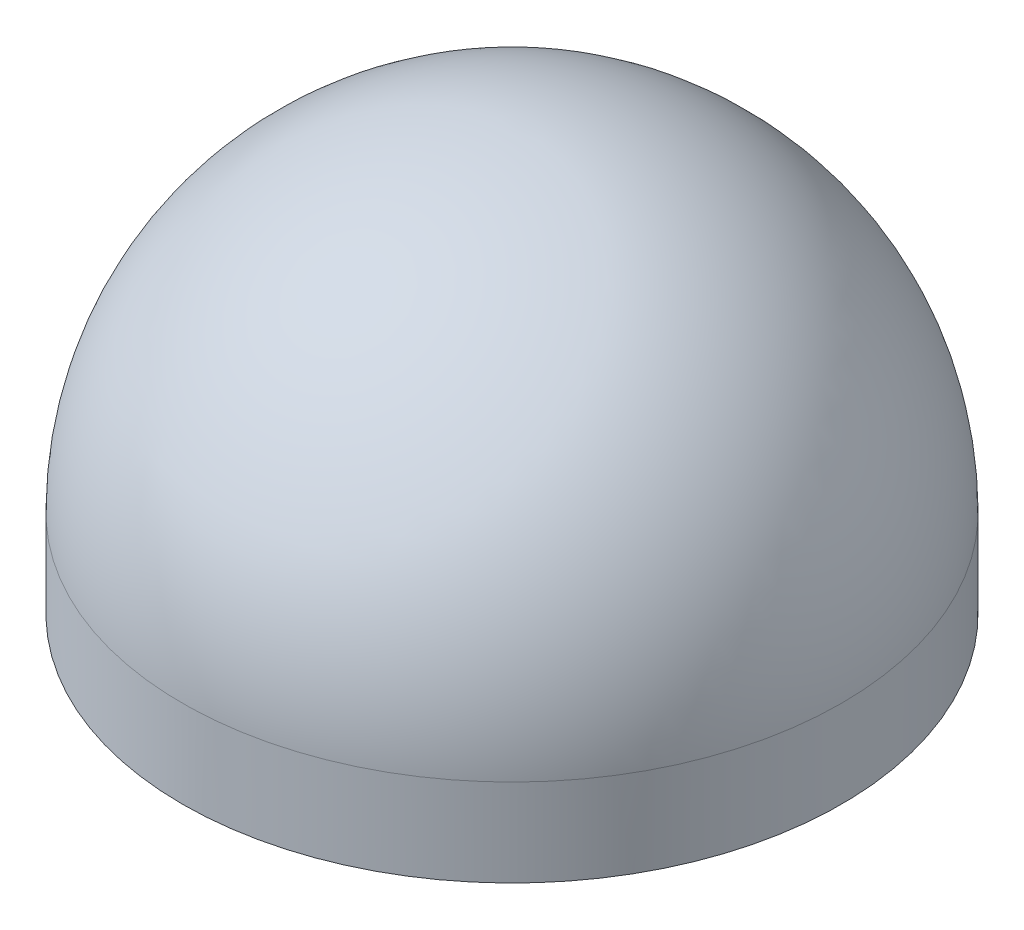
from build123d import *


with BuildPart() as part:
    # Sketch1 → Revolve1 (revolve)
    with BuildSketch(Plane.XY):
        with BuildLine():
            Line((-1.5875, 0), (-22.225, 0))
            Line((-22.225, 0), (-22.225, 5.896631452))
            ThreePointArc((-22.225, 5.896631452), (-15.715448212, 21.612079664), (0, 28.121631452))
            Line((0, 28.121631452), (0, 24.946631452))
            Line((0, 24.946631452), (-6.35, 24.946631452))
            Line((-6.35, 24.946631452), (-21.1836, 3.76205518))
            Line((-21.1836, 3.76205518), (-21.1836, 2.1082))
            Line((-21.1836, 2.1082), (-6.35, 2.1082))
            Line((-6.35, 2.1082), (-6.35, 6.35))
            Line((-6.35, 6.35), (-1.5875, 6.35))
            Line((-1.5875, 6.35), (-1.5875, 2.1082))
            Line((-1.5875, 2.1082), (-1.5875, 0))
        make_face()
    revolve(axis=Axis((0, 0, 0), (0, 1, 0)))


solid = part.part
